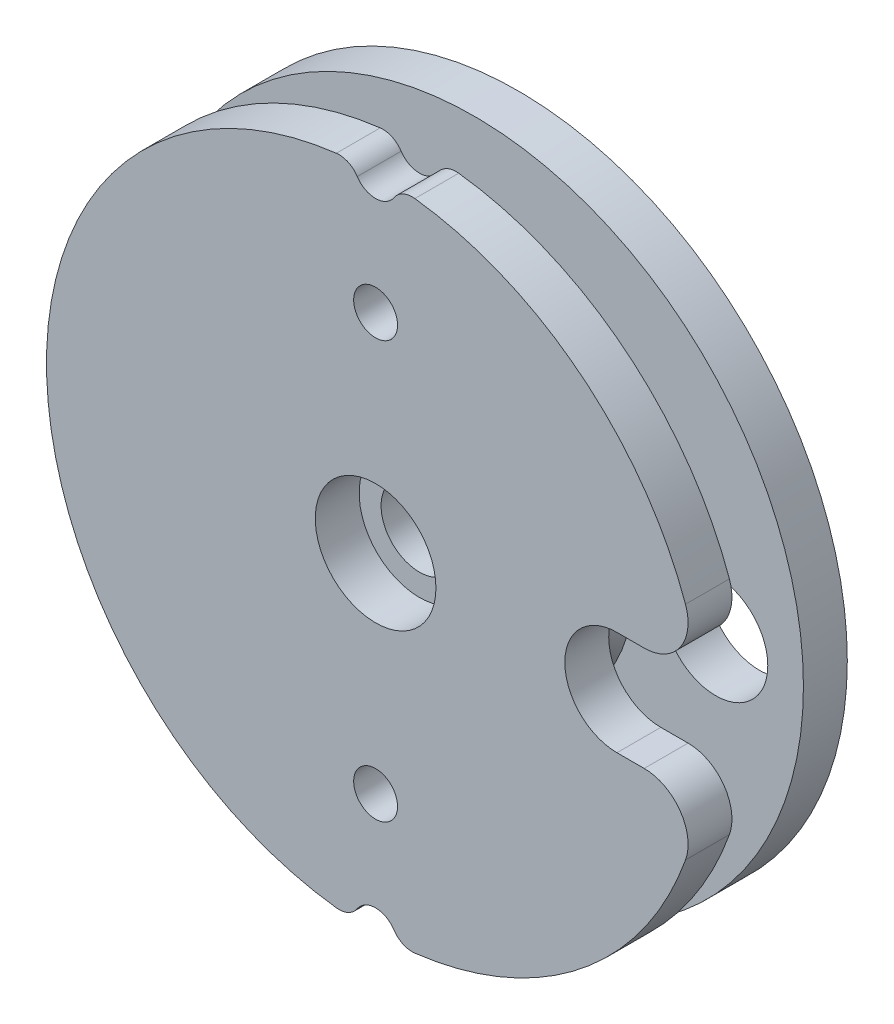
from build123d import *

# Parameters (mm, degrees)
SKETCH1_R                       = 15
BODY_DEPTH                      = 3.25
SKETCH2_R                       = 15
SKETCH2_R_2                     = 6.5
PULLEY_CLEARANCE_DEPTH          = 1.25
SKETCH3_R                       = 1.75
MAIN_BOLT_THROUGH_HOLE_DEPTH    = 7.5
SKETCH4_R                       = 5.25
SERVO_HORN_CLEARANCE_DEPTH      = 1.8
SKETCH5_R                       = 2.75
MAIN_BOLT_CLEARANCE_DEPTH       = 2
SKETCH6_R                       = 2.375
HORN_ATTACHMENT_HOLES_DEPTH     = 7.5
HORN_ATTACHMENT_CLEARANCE_DEPTH = 2
SKETCH8_R                       = 1
TENDON_ANCHOR_DEPTH             = 2
CONTOURING_BOLT_R               = 2
INNER_CHAMFER_SIZE              = 0.75
CONTOURING_TENDON_R             = 1
SKETCH9_R                       = 1.15
LOCKING_NUBS_DEPTH              = 0.7
NUB_CHAMFERS_SIZE               = 0.3


with BuildPart() as part:
    # Sketch1 → Body (new body, symmetric)
    with BuildSketch(Plane.XY):
        Circle(SKETCH1_R)
    extrude(amount=BODY_DEPTH, both=True)

    # Sketch2 → Pulley Clearance (cut, symmetric)
    with BuildSketch(Plane.XY):
        Circle(SKETCH2_R)
        Circle(SKETCH2_R_2, mode=Mode.SUBTRACT)
    extrude(amount=PULLEY_CLEARANCE_DEPTH, both=True, mode=Mode.SUBTRACT)

    # Sketch3 → Main Bolt Through Hole (cut, through all)
    with BuildSketch(Plane.XY.offset(3.25)):
        Circle(SKETCH3_R)
    extrude(amount=-MAIN_BOLT_THROUGH_HOLE_DEPTH, mode=Mode.SUBTRACT)

    # Sketch4 → Servo Horn Clearance (cut)
    with BuildSketch(Plane(origin=(0, 0, -3.25), x_dir=(-1, 0, 0), z_dir=(0, 0, -1))):
        Circle(SKETCH4_R)
    extrude(amount=-SERVO_HORN_CLEARANCE_DEPTH, mode=Mode.SUBTRACT)

    # Sketch5 → Main Bolt Clearance (cut)
    with BuildSketch(Plane.XY.offset(3.25)):
        Circle(SKETCH5_R)
    extrude(amount=-MAIN_BOLT_CLEARANCE_DEPTH, mode=Mode.SUBTRACT)

    # Sketch6 → Horn Attachment Holes (cut, through all)
    with BuildSketch(Plane(origin=(0, 0, -3.25), x_dir=(-1, 0, 0), z_dir=(0, 0, -1))):
        with Locations((-11, 0)):
            Circle(SKETCH6_R)
    extrude(amount=-HORN_ATTACHMENT_HOLES_DEPTH, mode=Mode.SUBTRACT)

    # Sketch7 → Horn Attachment Clearance (cut)
    with BuildSketch(Plane.XY.offset(3.25)):
        with BuildLine():
            Line((11, -2.375), (11, 2.375))
            Line((11, 2.375), (14.810785766, 2.375))
            ThreePointArc((14.810785766, 2.375), (15, 0), (14.810785766, -2.375))
            Line((14.810785766, -2.375), (11, -2.375))
        make_face()
    extrude(amount=-HORN_ATTACHMENT_CLEARANCE_DEPTH, mode=Mode.SUBTRACT)

    # Sketch8 → Tendon Anchor (cut)
    with BuildSketch(Plane.XY.offset(3.25)):
        with Locations((0, 9.5)):
            Circle(SKETCH8_R)
        with Locations((0, 15)):
            Circle(SKETCH8_R)
        with Locations((0, -15)):
            Circle(SKETCH8_R)
        with Locations((0, -9.5)):
            Circle(SKETCH8_R)
    extrude(amount=-TENDON_ANCHOR_DEPTH, mode=Mode.SUBTRACT)

    # Contouring - Bolt
    contouring_bolt_edges = [part.edges().sort_by_distance(p)[0] for p in [
        (14.810785766, -2.375, 2.25),
        (14.810785766, 2.375, 2.25),
    ]]
    fillet(contouring_bolt_edges, radius=CONTOURING_BOLT_R)

    # Inner Chamfer
    inner_chamfer_edges = [part.edges().sort_by_distance(p)[0] for p in [
        (-6.5, 0, -1.25),
        (-6.5, 0, 1.25),
    ]]
    chamfer(inner_chamfer_edges, length=INNER_CHAMFER_SIZE)

    # Contouring - Tendon
    contouring_tendon_edges = [part.edges().sort_by_distance(p)[0] for p in [
        (-0.99944429, 14.966666667, 2.25),
        (0.99944429, 14.966666667, 2.25),
        (0.99944429, -14.966666667, 2.25),
        (-0.99944429, -14.966666667, 2.25),
    ]]
    fillet(contouring_tendon_edges, radius=CONTOURING_TENDON_R)

    # Sketch9 → Locking Nubs (add)
    with BuildSketch(Plane(origin=(0, 0, -3.25), x_dir=(-1, 0, 0), z_dir=(0, 0, -1))):
        with Locations((11, 0)):
            Circle(SKETCH9_R)
        with Locations((7.778174593, -7.778174593)):
            Circle(SKETCH9_R)
        with Locations((0, -11)):
            Circle(SKETCH9_R)
        with Locations((-7.778174593, -7.778174593)):
            Circle(SKETCH9_R)
        with Locations((-7.778174593, 7.778174593)):
            Circle(SKETCH9_R)
        with Locations((0, 11)):
            Circle(SKETCH9_R)
        with Locations((7.778174593, 7.778174593)):
            Circle(SKETCH9_R)
    extrude(amount=LOCKING_NUBS_DEPTH)

    # Nub Chamfers
    nub_chamfers_edges = [part.edges().sort_by_distance(p)[0] for p in [
        (-9.85, 0, -3.95),
        (-6.628174593, -7.778174593, -3.95),
        (1.15, -11, -3.95),
        (8.928174593, -7.778174593, -3.95),
        (8.928174593, 7.778174593, -3.95),
        (1.15, 11, -3.95),
        (-6.628174593, 7.778174593, -3.95),
    ]]
    chamfer(nub_chamfers_edges, length=NUB_CHAMFERS_SIZE)


solid = part.part
